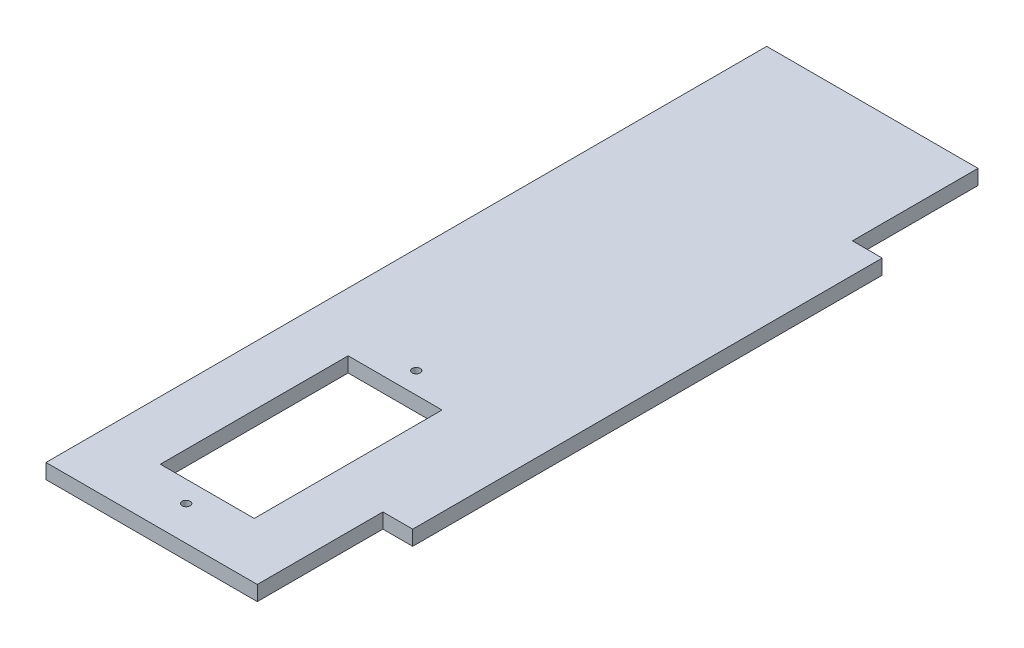
from build123d import *

# Parameters (mm, degrees)
BOSS_EXTRUDE1_DEPTH    = 3.175
SKETCH3_W              = 20
SKETCH3_H              = 40
CUT_EXTRUDE1_DEPTH     = 131.03063341
M1_6_CLEARANCE_HOLE1_D = 1.7


with BuildPart() as part:
    # Sketch1 → Boss-Extrude1 (new body)
    with BuildSketch(Plane(origin=(0, 0, 0), x_dir=(1, 0, 0), z_dir=(0, 1, 0))):
        Polygon((-22.5, 0), (-22.5, 26.75), (22.5, 26.75), (22.5, 0), (28.85, 0), (28.85, -100), (22.5, -100), (22.5, -126.75), (-22.5, -126.75), (-22.5, -100), align=None)
    extrude(amount=BOSS_EXTRUDE1_DEPTH)

    # Sketch3 → Cut-Extrude1 (cut, through all)
    with BuildSketch(Plane(origin=(0, 3.175, 0), x_dir=(1, 0, 0), z_dir=(0, 1, 0))):
        with Locations((0, -94.9)):
            Rectangle(SKETCH3_W, SKETCH3_H)
    extrude(amount=-CUT_EXTRUDE1_DEPTH, mode=Mode.SUBTRACT)

    # M1.6 Clearance Hole1 (through all)
    with Locations(Plane(origin=(0, 3.175, 0), x_dir=(1, 0, 0), z_dir=(0, 1, 0))):
        with Locations((0, -70.4), (0, -119.4)):
            Hole(M1_6_CLEARANCE_HOLE1_D / 2)


solid = part.part
